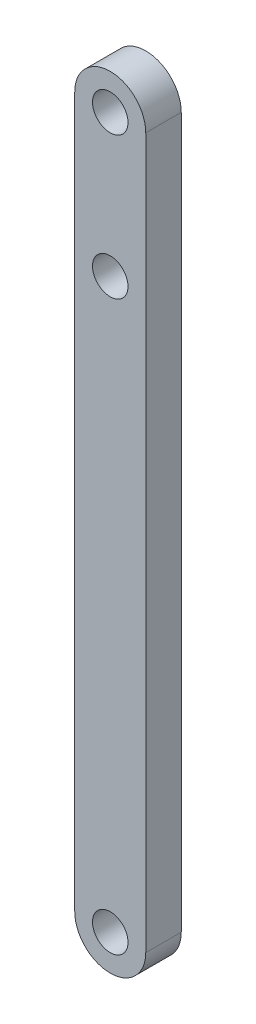
from build123d import *

# Parameters (mm, degrees)
EXTRUDE_1_DEPTH     = 3
SKETCH_3_R          = 1.5
CUT_EXTRUDE_3_DEPTH = 5


with BuildPart() as part:
    # 草图1 → 凸台-拉伸1 (new body)
    with BuildSketch(Plane.XY):
        with BuildLine():
            Line((0, 0), (0, 60))
            ThreePointArc((0, 60), (3, 63), (6, 60))
            Line((6, 60), (6, 0))
            ThreePointArc((6, 0), (3, -3), (0, 0))
        make_face()
    extrude(amount=EXTRUDE_1_DEPTH)

    # 草图3 → 切除-拉伸3 (cut)
    with BuildSketch(Plane.XY):
        with Locations((3, 0)):
            Circle(SKETCH_3_R)
        with Locations((3, 60)):
            Circle(SKETCH_3_R)
        with Locations((3, 48)):
            Circle(SKETCH_3_R)
    extrude(amount=CUT_EXTRUDE_3_DEPTH, mode=Mode.SUBTRACT)


solid = part.part
